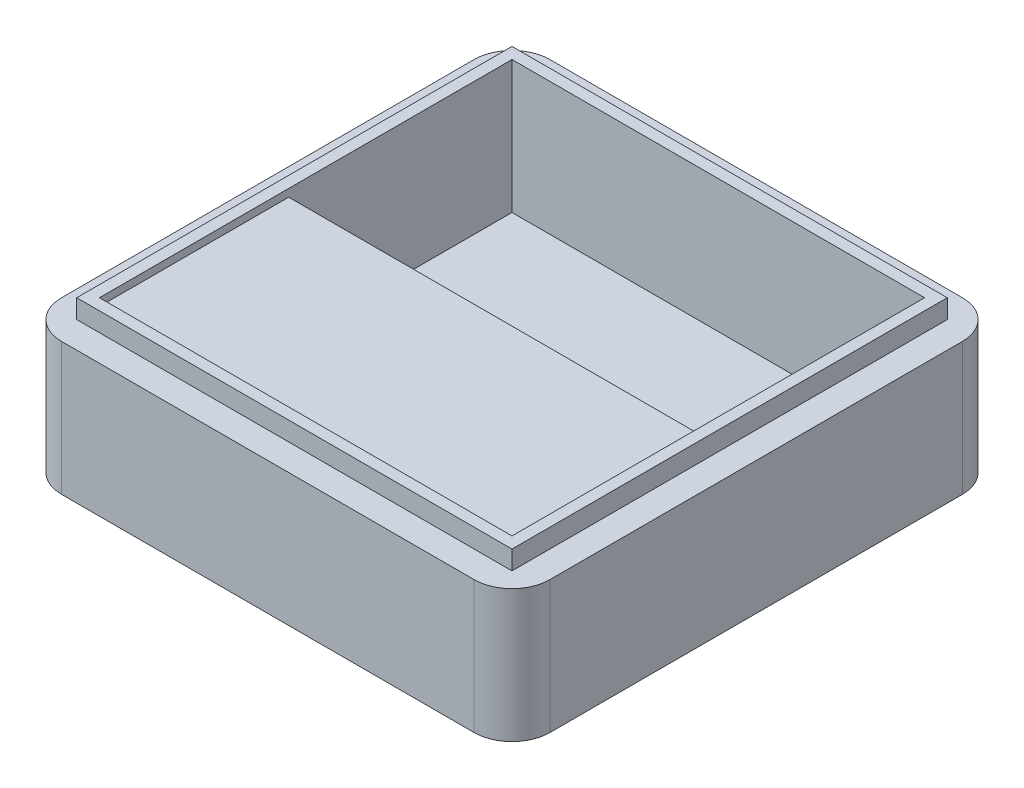
from build123d import *

# Parameters (mm, degrees)
SKETCH1_W           = 115
SKETCH1_H           = 115
BOSS_EXTRUDE2_DEPTH = 5
SKETCH3_W           = 129
SKETCH3_H           = 129
BOSS_EXTRUDE3_DEPTH = 35
SKETCH4_W           = 109
SKETCH4_H           = 109
CUT_EXTRUDE1_DEPTH  = 35
FILLET1_R           = 10
SKETCH6_W           = 109
SKETCH6_H           = 33
BOSS_EXTRUDE5_DEPTH = 50


with BuildPart() as part:
    # Sketch1 → Boss-Extrude2 (new body)
    with BuildSketch(Plane(origin=(0, 0, 0), x_dir=(1, 0, 0), z_dir=(0, 1, 0))):
        Rectangle(SKETCH1_W, SKETCH1_H)
    extrude(amount=BOSS_EXTRUDE2_DEPTH)

    # Sketch3 → Boss-Extrude3 (add)
    with BuildSketch(Plane.XZ):
        Rectangle(SKETCH3_W, SKETCH3_H)
    extrude(amount=BOSS_EXTRUDE3_DEPTH)

    # Sketch4 → Cut-Extrude1 (cut)
    with BuildSketch(Plane(origin=(0, 5, 0), x_dir=(1, 0, 0), z_dir=(0, 1, 0))):
        Rectangle(SKETCH4_W, SKETCH4_H)
    extrude(amount=-CUT_EXTRUDE1_DEPTH, mode=Mode.SUBTRACT)

    # Fillet1
    fillet1_edges = [part.edges().sort_by_distance(p)[0] for p in [
        (64.5, -17.5, -64.5),
        (64.5, -17.5, 64.5),
        (-64.5, -17.5, 64.5),
        (-64.5, -17.5, -64.5),
    ]]
    fillet(fillet1_edges, radius=FILLET1_R)

    # Sketch6 → Boss-Extrude5 (add)
    with BuildSketch(Plane(origin=(0, 0, 54.5), x_dir=(-1, 0, 0), z_dir=(0, 0, -1))):
        with Locations((0, -13.5)):
            Rectangle(SKETCH6_W, SKETCH6_H)
    extrude(amount=BOSS_EXTRUDE5_DEPTH)


solid = part.part
